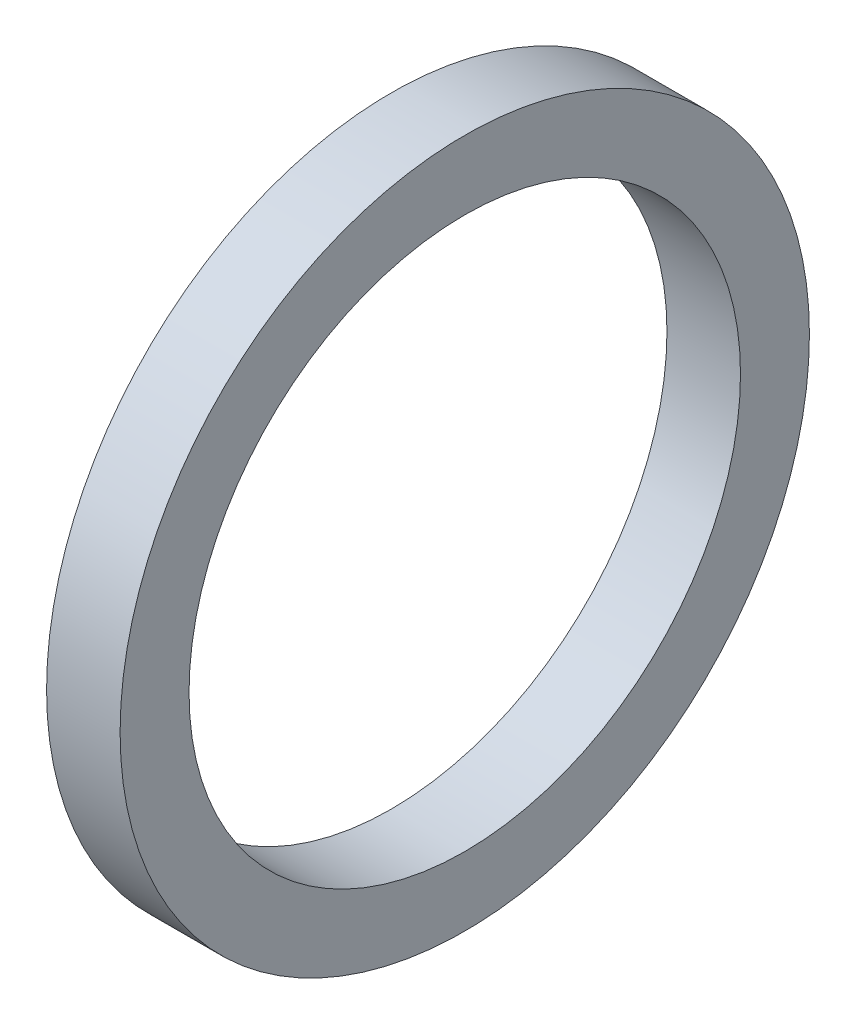
from build123d import *

# Parameters (mm, degrees)
SKETCH1_W = 2.032
SKETCH1_H = 1.905


with BuildPart() as part:
    # Sketch1 → Revolve1 (revolve)
    with BuildSketch(Plane.XY, mode=Mode.PRIVATE) as revolve1_sk:
        with Locations((1.016, -8.5725)):
            Rectangle(SKETCH1_W, SKETCH1_H)
    revolve(revolve1_sk.sketch.rotate(Axis((-43.716580756, 0, 0), (1, 0, 0)), 270), axis=Axis((-43.716580756, 0, 0), (1, 0, 0)))  # turned: the seam where the file's is


solid = part.part
